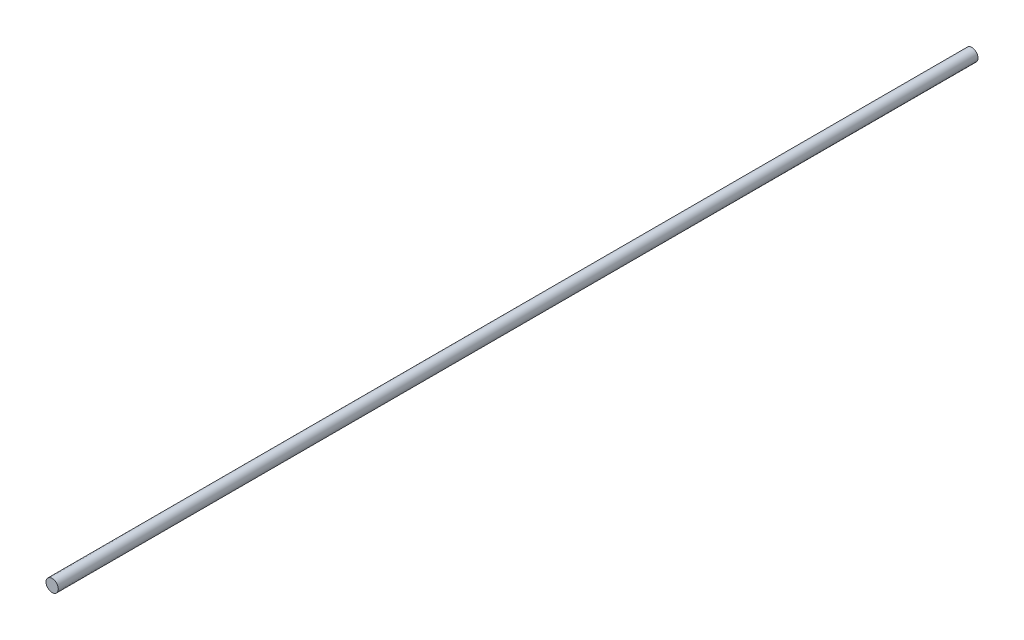
from build123d import *

# Parameters (mm, degrees)
SKETCH1_R           = 3.175
BOSS_EXTRUDE1_DEPTH = 475


with BuildPart() as part:
    # Sketch1 → Boss-Extrude1 (new body)
    with BuildSketch(Plane.XY):
        Circle(SKETCH1_R)
    extrude(amount=BOSS_EXTRUDE1_DEPTH)


solid = part.part
